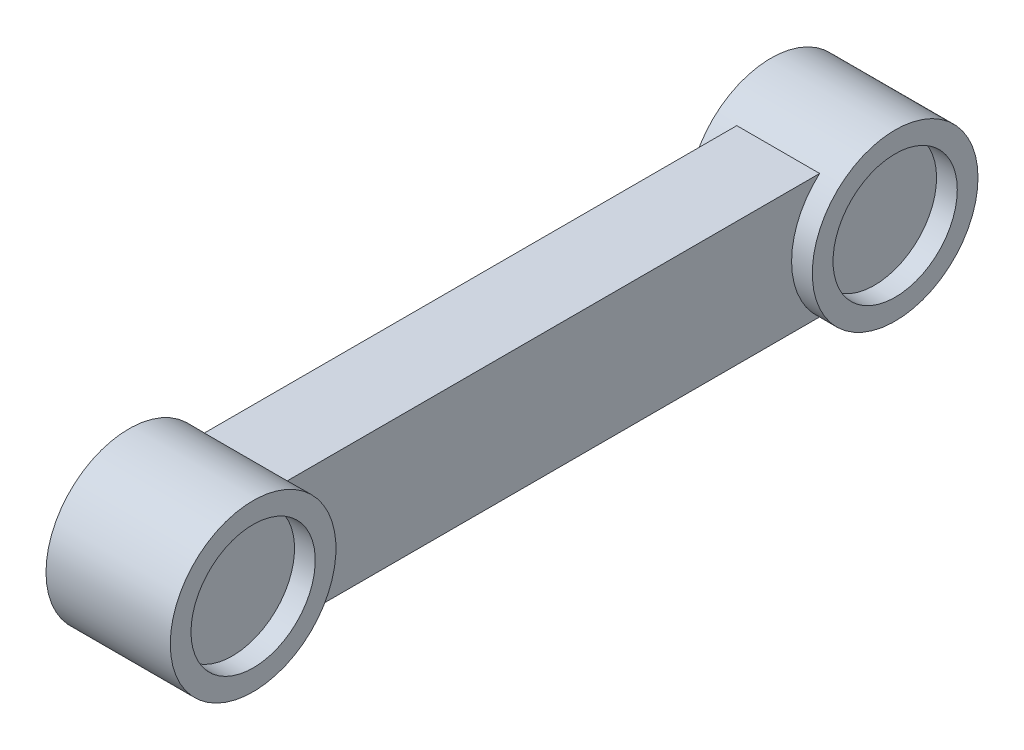
from build123d import *

# Parameters (mm, degrees)
SKETCH1_R             = 40
BOSS_EXTRUDE1_DEPTH   = 60
BOSS_EXTRUDE1_2_DEPTH = 60
BOSS_EXTRUDE2_START   = -121.840385
SKETCH5_W             = 40
SKETCH5_H             = 60
BOSS_EXTRUDE2_DEPTH   = 257.063378
SKETCH7_R             = 6
CUT_EXTRUDE5_DEPTH    = 10
SKETCH8_R             = 6
BOSS_EXTRUDE3_DEPTH   = 10
SKETCH2_R             = 30
CUT_EXTRUDE6_DEPTH    = 10


with BuildPart() as part:
    # Sketch1 → Boss-Extrude1 (new body)
    with BuildSketch(Plane(origin=(0, 0, 0), x_dir=(0, 0, -1), z_dir=(1, 0, 0))):
        Circle(SKETCH1_R)
    extrude(amount=BOSS_EXTRUDE1_DEPTH)



with BuildPart() as body_2:
    # Sketch1 → Boss-Extrude1 2 (new body)
    with BuildSketch(Plane(origin=(0, 0, 0), x_dir=(0, 0, -1), z_dir=(1, 0, 0))):
        with Locations((-309.978404015, 0)):
            Circle(SKETCH1_R)
    extrude(amount=BOSS_EXTRUDE1_2_DEPTH)


with BuildPart() as part_1:
    add(part.part)

    add(body_2.part)  # Boss-Extrude2 merges body 2
    # Sketch5 → Boss-Extrude2 (add)
    with BuildSketch(Plane(origin=(0, 0, 161.680506403), x_dir=(-1, 0, 0), z_dir=(0, 0, -1)).offset(BOSS_EXTRUDE2_START)):
        with Locations((-30, 0)):
            Rectangle(SKETCH5_W, SKETCH5_H)
    extrude(amount=BOSS_EXTRUDE2_DEPTH)

    # Sketch7 → Cut-Extrude5 (cut)
    with BuildSketch(Plane.ZY):
        Circle(SKETCH7_R)
    extrude(amount=-CUT_EXTRUDE5_DEPTH, mode=Mode.SUBTRACT)

    # Sketch8 → Boss-Extrude3 (add)
    with BuildSketch(Plane.ZY):
        with Locations((309.978404015, 0)):
            Circle(SKETCH8_R)
    extrude(amount=BOSS_EXTRUDE3_DEPTH)

    # Sketch2 → Cut-Extrude6 (cut)
    with BuildSketch(Plane(origin=(60, 0, 0), x_dir=(0, 0, -1), z_dir=(1, 0, 0))):
        Circle(SKETCH2_R)
        with Locations((-309.978404015, 0)):
            Circle(SKETCH2_R)
    extrude(amount=-CUT_EXTRUDE6_DEPTH, mode=Mode.SUBTRACT)


solid = part_1.part
